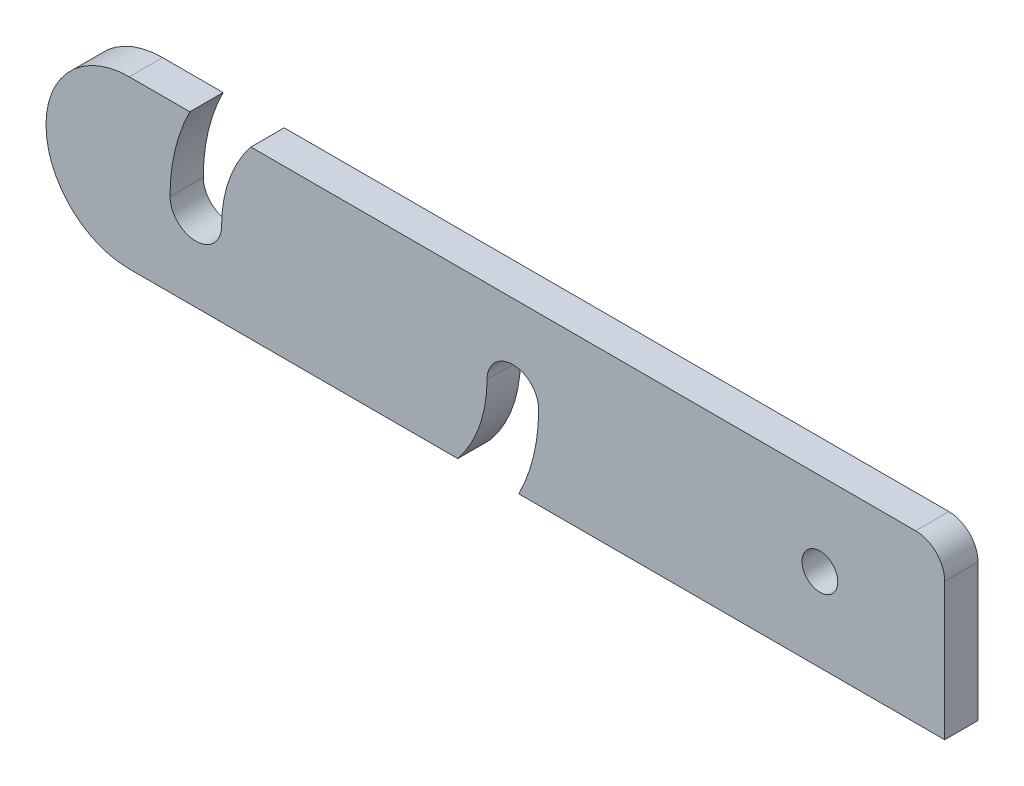
from build123d import *

# Parameters (mm, degrees)
SKETCH1_R           = 2.15
BOSS_EXTRUDE1_DEPTH = 4


with BuildPart() as part:
    # Sketch1 → Boss-Extrude1 (new body)
    with BuildSketch(Plane.XY):
        with BuildLine():
            Line((20.7866022, -13), (-18.694986916, -13))
            ThreePointArc((-18.694986916, -13), (-28.694986916, -3), (-18.694986916, 7))
            Line((-18.694986916, 7), (-11.409460793, 7))
            ThreePointArc((-11.409460793, 7), (-13.190353922, 2.140299964), (-13.794986916, -3))
            ThreePointArc((-13.794986916, -3), (-10.694986916, -6.1), (-7.594986916, -3))
            ThreePointArc((-7.594986916, -3), (-6.688371741, 2.301283436), (-4.071576031, 7))
            Line((-4.071576031, 7), (75.805013084, 7))
            ThreePointArc((75.805013084, 7), (78.279886819, 5.974873734), (79.305013084, 3.5))
            Line((79.305013084, 3.5), (79.305013084, -13))
            Line((79.305013084, -13), (28.124486961, -13))
            ThreePointArc((28.124486961, -13), (29.905380091, -8.140299964), (30.510013084, -3))
            ThreePointArc((30.510013084, -3), (27.410013084, 0.1), (24.310013084, -3))
            ThreePointArc((24.310013084, -3), (23.40339791, -8.301283436), (20.7866022, -13))
        make_face()
        with Locations((64.305013084, -3)):
            Circle(SKETCH1_R, mode=Mode.SUBTRACT)
    extrude(amount=BOSS_EXTRUDE1_DEPTH)


solid = part.part
